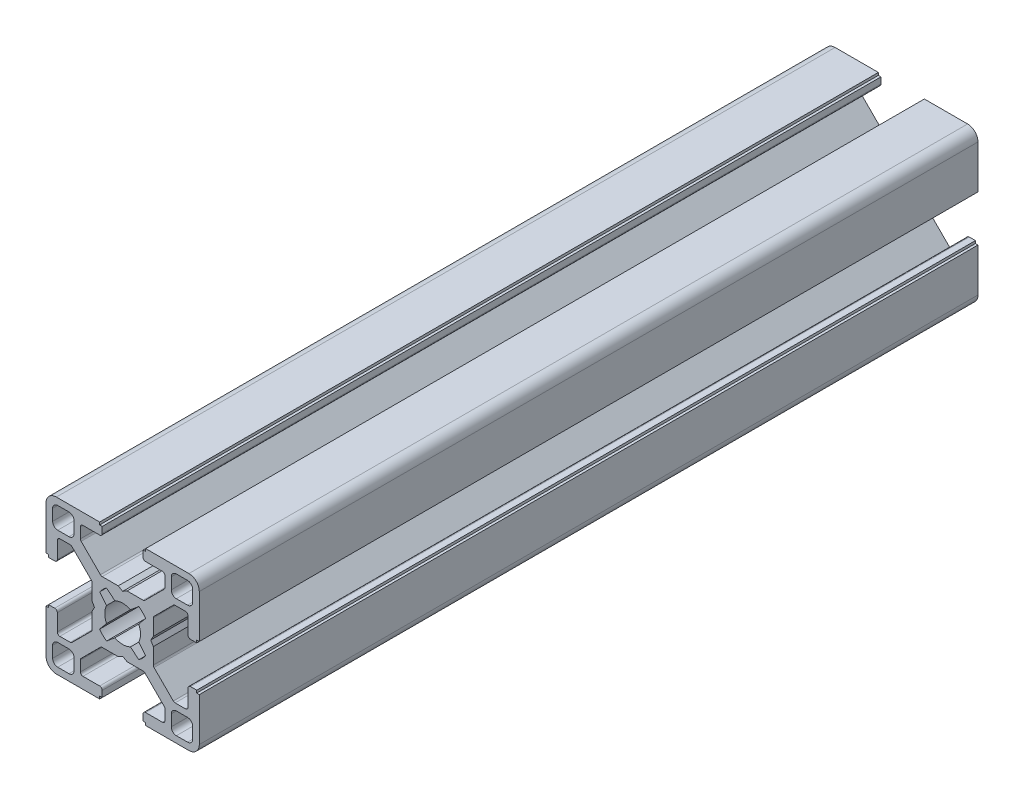
from build123d import *

# Parameters (mm, degrees)
BOSS_EXTRUDE1_DEPTH = 76.2
CIRPATTERN1_COUNT   = 4


with BuildPart() as part:
    # Sketch3 → Boss-Extrude1 (new body, symmetric)
    with BuildSketch(Plane.XY):
        with BuildLine():
            Line((-4.503841895, 3.156803476), (-3.14772708, 1.530298739))
            ThreePointArc((-3.14772708, 1.530298739), (-3.410794979, 0.785160882), (-3.5, 0))
            Line((-3.5, 0), (-5.5, 0))
            Line((-5.5, 0), (-6, 0.866025404))
            Line((-6, 0.866025404), (-6, 3.996841995))
            ThreePointArc((-6, 3.996841995), (-6.038060234, 4.188183711), (-6.146446609, 4.350395385))
            Line((-6.146446609, 4.350395385), (-9.917104615, 8.121053391))
            ThreePointArc((-9.917104615, 8.121053391), (-10.079316289, 8.229439766), (-10.270658005, 8.2675))
            Line((-10.270658005, 8.2675), (-12.29, 8.2675))
            ThreePointArc((-12.29, 8.2675), (-12.643553391, 8.121053391), (-12.79, 7.7675))
            Line((-12.79, 7.7675), (-12.79, 4.5))
            ThreePointArc((-12.79, 4.5), (-12.936446609, 4.146446609), (-13.29, 4))
            Line((-13.29, 4), (-14.5, 4))
            Line((-14.5, 4), (-14.5, 4.5))
            Line((-14.5, 4.5), (-15, 4.5))
            Line((-15, 4.5), (-15, 12.968))
            ThreePointArc((-15, 12.968), (-14.404840979, 14.404840979), (-12.968, 15))
            Line((-12.968, 15), (-4.5, 15))
            Line((-4.5, 15), (-4.5, 14.5))
            Line((-4.5, 14.5), (-4, 14.5))
            Line((-4, 14.5), (-4, 13.29))
            ThreePointArc((-4, 13.29), (-4.146446609, 12.936446609), (-4.5, 12.79))
            Line((-4.5, 12.79), (-7.7675, 12.79))
            ThreePointArc((-7.7675, 12.79), (-8.121053391, 12.643553391), (-8.2675, 12.29))
            Line((-8.2675, 12.29), (-8.2675, 10.270658005))
            ThreePointArc((-8.2675, 10.270658005), (-8.229439766, 10.079316289), (-8.121053391, 9.917104615))
            Line((-8.121053391, 9.917104615), (-4.350395385, 6.146446609))
            ThreePointArc((-4.350395385, 6.146446609), (-4.188183711, 6.038060234), (-3.996841995, 6))
            Line((-3.996841995, 6), (-0.866025404, 6))
            Line((-0.866025404, 6), (0, 5.5))
            Line((0, 5.5), (0, 3.5))
            ThreePointArc((0, 3.5), (-0.785160882, 3.410794979), (-1.530298739, 3.14772708))
            Line((-1.530298739, 3.14772708), (-3.156803476, 4.503841895))
            ThreePointArc((-3.156803476, 4.503841895), (-3.889087297, 3.889087297), (-4.503841895, 3.156803476))
        make_face()
        with BuildLine():
            Line((-12.705, 9.5135), (-10.5135, 9.5135))
            ThreePointArc((-10.5135, 9.5135), (-9.806393219, 9.806393219), (-9.5135, 10.5135))
            Line((-9.5135, 10.5135), (-9.5135, 12.705))
            ThreePointArc((-9.5135, 12.705), (-9.806393219, 13.412106781), (-10.5135, 13.705))
            Line((-10.5135, 13.705), (-12.705, 13.705))
            ThreePointArc((-12.705, 13.705), (-13.412106781, 13.412106781), (-13.705, 12.705))
            Line((-13.705, 12.705), (-13.705, 10.5135))
            ThreePointArc((-13.705, 10.5135), (-13.412106781, 9.806393219), (-12.705, 9.5135))
        make_face(mode=Mode.SUBTRACT)
    boss_extrude1 = extrude(amount=BOSS_EXTRUDE1_DEPTH, both=True)

    # CirPattern1: Boss-Extrude1 ×4 about axis
    cirpattern1_axis = Axis((0, 0, 0), (0, 0, 1))
    for i in range(1, CIRPATTERN1_COUNT):
        add(boss_extrude1.rotate(cirpattern1_axis, i * 360 / CIRPATTERN1_COUNT))


solid = part.part
